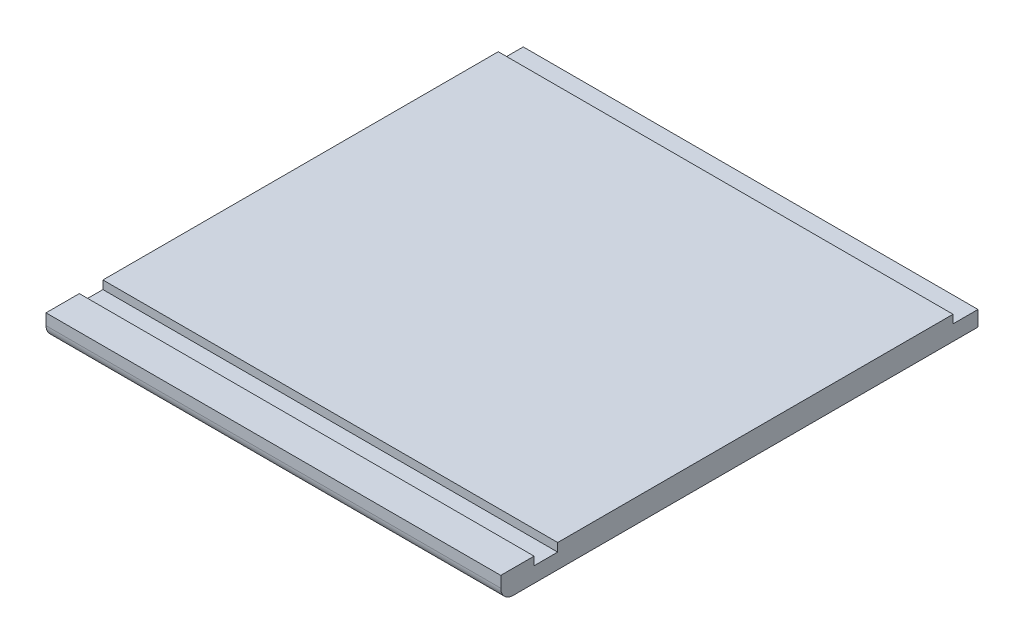
from build123d import *

# Parameters (mm, degrees)
SKETCH1_W           = 346.7
SKETCH1_H           = 376.55000001
BOSS_EXTRUDE1_DEPTH = 18
SKETCH2_W           = 346.7
SKETCH2_H           = 18
CUT_EXTRUDE1_DEPTH  = 6.35
FILLET1_R           = 9.525
SKETCH3_W           = 346.7
SKETCH3_H           = 19.05
CUT_EXTRUDE2_DEPTH  = 6.35
SKETCH4_W           = 346.7
SKETCH4_H           = 12.7
CUT_EXTRUDE3_DEPTH  = 19
FILLET2_R           = 9.525


with BuildPart() as part:
    # Sketch1 → Boss-Extrude1 (new body)
    with BuildSketch(Plane(origin=(0, 0, 0), x_dir=(1, 0, 0), z_dir=(0, 1, 0))):
        with Locations((173.35, -188.275000005)):
            Rectangle(SKETCH1_W, SKETCH1_H)
    extrude(amount=BOSS_EXTRUDE1_DEPTH)

    # Sketch2 → Cut-Extrude1 (cut)
    with BuildSketch(Plane(origin=(0, 18, 0), x_dir=(1, 0, 0), z_dir=(0, 1, 0))):
        with Locations((173.35, -329.45000001)):
            Rectangle(SKETCH2_W, SKETCH2_H)
    extrude(amount=-CUT_EXTRUDE1_DEPTH, mode=Mode.SUBTRACT)

    # Fillet1
    fillet1_edges = [part.edges().sort_by_distance(p)[0] for p in [
        (173.35, 0, 376.55000001),
    ]]
    fillet(fillet1_edges, radius=FILLET1_R)

    # Sketch3 → Cut-Extrude2 (cut)
    with BuildSketch(Plane(origin=(0, 18, 0), x_dir=(1, 0, 0), z_dir=(0, 1, 0))):
        with Locations((173.35, -9.525)):
            Rectangle(SKETCH3_W, SKETCH3_H)
    extrude(amount=-CUT_EXTRUDE2_DEPTH, mode=Mode.SUBTRACT)

    # Sketch4 → Cut-Extrude3 (cut, through all)
    with BuildSketch(Plane(origin=(0, 18, 0), x_dir=(1, 0, 0), z_dir=(0, 1, 0))):
        with Locations((173.35, -370.20000001)):
            Rectangle(SKETCH4_W, SKETCH4_H)
    extrude(amount=-CUT_EXTRUDE3_DEPTH, mode=Mode.SUBTRACT)

    # Fillet2
    fillet2_edges = [part.edges().sort_by_distance(p)[0] for p in [
        (173.35, 0, 363.85000001),
    ]]
    fillet(fillet2_edges, radius=FILLET2_R)


solid = part.part
